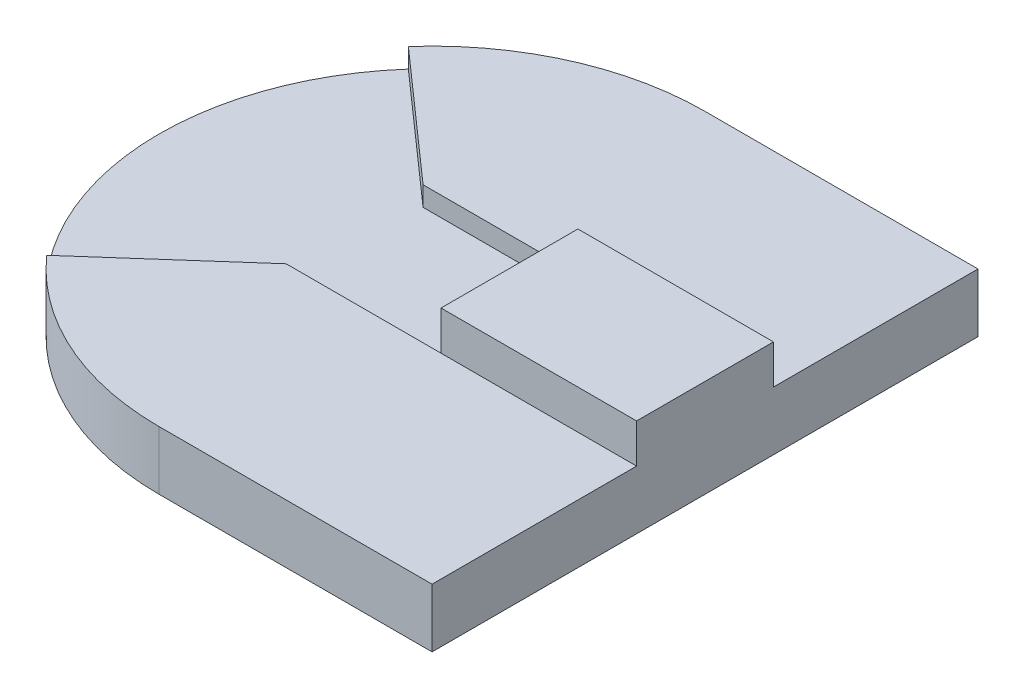
from build123d import *

# Parameters (mm, degrees)
BOSS_EXTRUDE2_DEPTH = 2
BOSS_EXTRUDE3_DEPTH = 3
SKETCH1_7_W         = 10
SKETCH1_7_H         = 7
BOSS_EXTRUDE5_DEPTH = 5


with BuildPart() as part:
    # Sketch1 → Boss-Extrude2 (new body)
    with BuildSketch(Plane(origin=(0, 0, 0), x_dir=(1, 0, 0), z_dir=(0, 1, 0))):
        with BuildLine():
            Line((-6.445352893, 3.5), (-14.362421277, 3.5))
            Line((-14.362421277, 3.5), (-20.861114748, 9.245921608))
            ThreePointArc((-20.861114748, 9.245921608), (-24.362421277, 0), (-20.861114748, -9.245921608))
            Line((-20.861114748, -9.245921608), (-14.362421277, -3.5))
            Line((-14.362421277, -3.5), (-6.445352893, -3.5))
            Line((-6.445352893, -3.5), (-6.445352893, 3.5))
        make_face()
    extrude(amount=BOSS_EXTRUDE2_DEPTH)

    # Sketch1_5 → Boss-Extrude3 (add)
    with BuildSketch(Plane(origin=(0, 0, 0), x_dir=(1, 0, 0), z_dir=(0, 1, 0))):
        with BuildLine():
            Line((3.554647107, 3.5), (3.554647107, 13.958534192))
            Line((3.554647107, 13.958534192), (-10.403887085, 13.958534192))
            ThreePointArc((-10.403887085, 13.958534192), (-16.138918204, 12.725961451), (-20.861114748, 9.245921608))
            Line((-20.861114748, 9.245921608), (-14.362421277, 3.5))
            Line((-14.362421277, 3.5), (3.554647107, 3.5))
        make_face()
        with BuildLine():
            Line((-14.362421277, -3.5), (-20.861114748, -9.245921608))
            ThreePointArc((-20.861114748, -9.245921608), (-16.138918204, -12.725961451), (-10.403887085, -13.958534192))
            Line((-10.403887085, -13.958534192), (3.554647107, -13.958534192))
            Line((3.554647107, -13.958534192), (3.554647107, -3.5))
            Line((3.554647107, -3.5), (-14.362421277, -3.5))
        make_face()
    extrude(amount=BOSS_EXTRUDE3_DEPTH)

    # Sketch1_7 → Boss-Extrude5 (add)
    with BuildSketch(Plane(origin=(0, 0, 0), x_dir=(1, 0, 0), z_dir=(0, 1, 0))):
        with Locations((-1.445352893, 0)):
            Rectangle(SKETCH1_7_W, SKETCH1_7_H)
    extrude(amount=BOSS_EXTRUDE5_DEPTH)


solid = part.part
